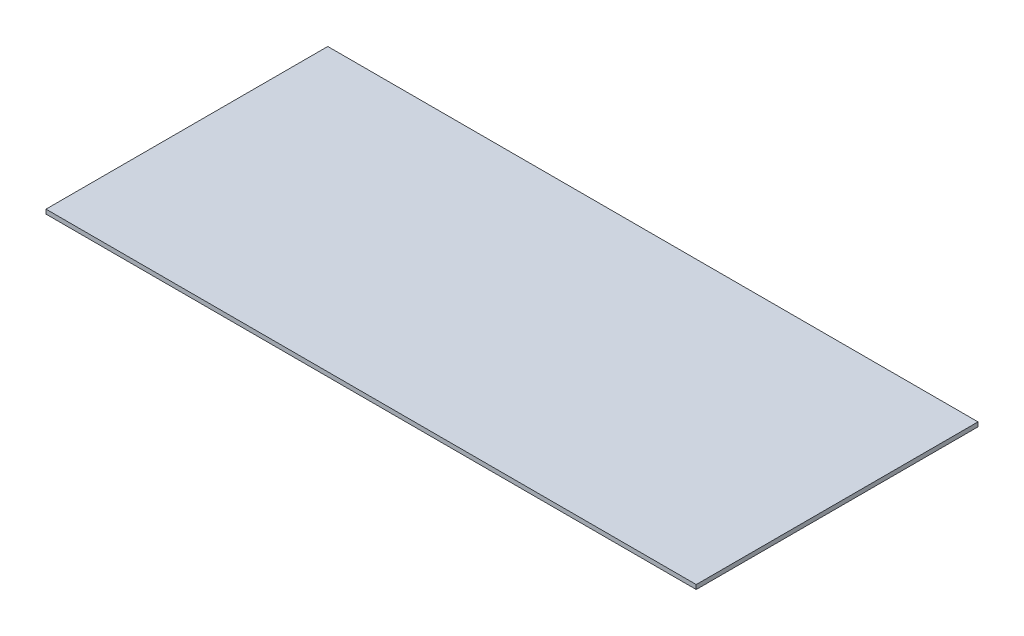
from build123d import *

# Parameters (mm, degrees)
SKETCH1_W           = 381
SKETCH1_H           = 165.1
BOSS_EXTRUDE1_DEPTH = 2.54


with BuildPart() as part:
    # Sketch1 → Boss-Extrude1 (new body)
    with BuildSketch(Plane(origin=(0, 0, 0), x_dir=(1, 0, 0), z_dir=(0, 1, 0))):
        Rectangle(SKETCH1_W, SKETCH1_H)
    extrude(amount=BOSS_EXTRUDE1_DEPTH)


solid = part.part
